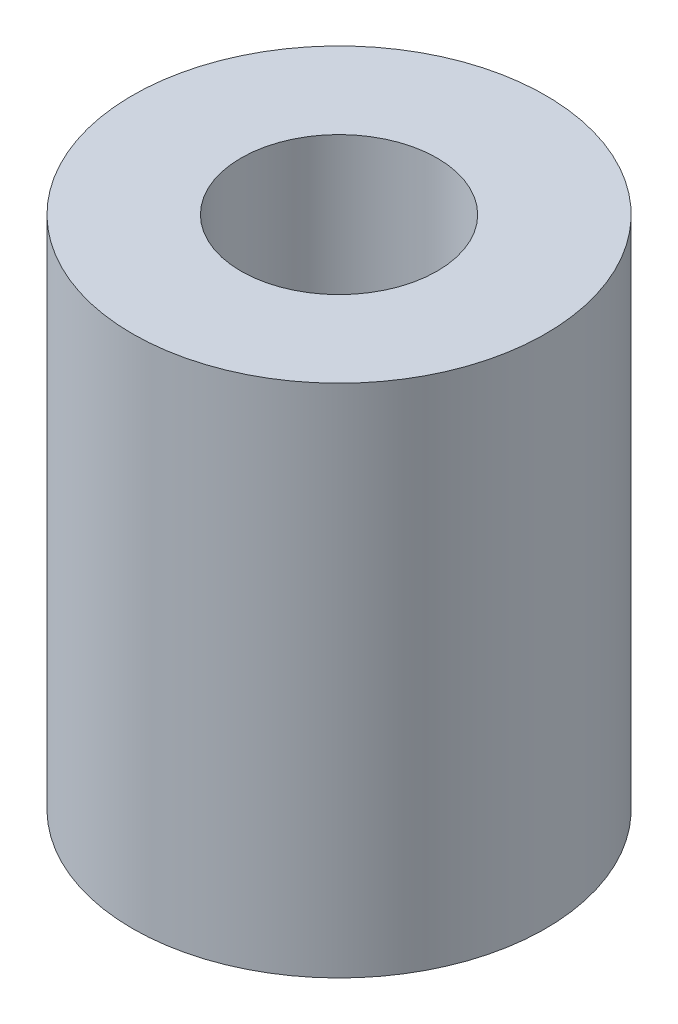
from build123d import *

# Parameters (mm, degrees)
SKETCH1_R           = 10.033
BOSS_EXTRUDE1_DEPTH = 25.019
SKETCH2_R           = 4
CUT_EXTRUDE1_DEPTH  = 10.16
SKETCH3_R           = 4.7625
CUT_EXTRUDE2_DEPTH  = 14.859


with BuildPart() as part:
    # Sketch1 → Boss-Extrude1 (new body)
    with BuildSketch(Plane(origin=(0, 0, 0), x_dir=(1, 0, 0), z_dir=(0, 1, 0))):
        Circle(SKETCH1_R)
    extrude(amount=BOSS_EXTRUDE1_DEPTH)

    # Sketch2 → Cut-Extrude1 (cut)
    with BuildSketch(Plane.XZ):
        Circle(SKETCH2_R)
    extrude(amount=-CUT_EXTRUDE1_DEPTH, mode=Mode.SUBTRACT)

    # Sketch3 → Cut-Extrude2 (cut)
    with BuildSketch(Plane(origin=(0, 25.019, 0), x_dir=(1, 0, 0), z_dir=(0, 1, 0))):
        Circle(SKETCH3_R)
    extrude(amount=-CUT_EXTRUDE2_DEPTH, mode=Mode.SUBTRACT)


solid = part.part
